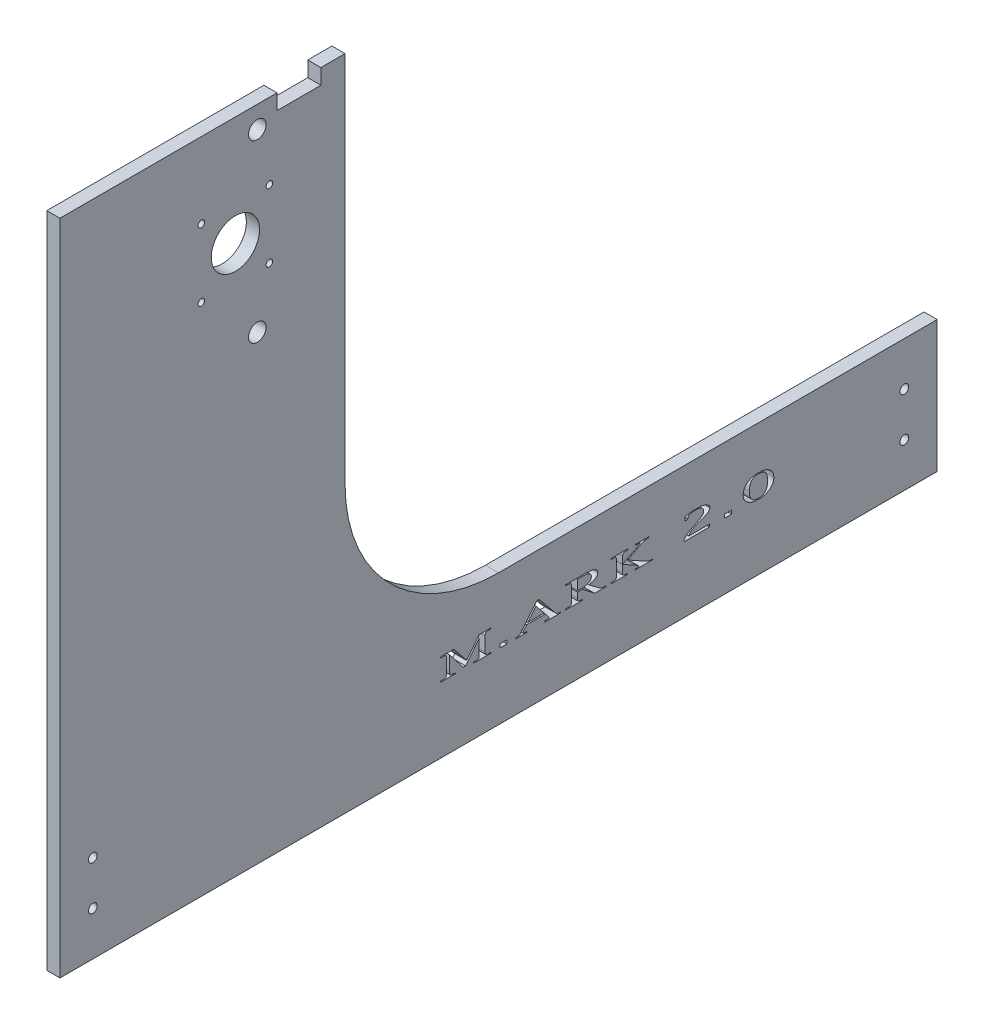
from build123d import *

# Parameters (mm, degrees)
SKETCH1_R           = 4
SKETCH1_R_2         = 1.5
SKETCH1_R_3         = 11
BOSS_EXTRUDE1_DEPTH = 6
SKETCH2_W           = 50
SKETCH2_H           = 300
BOSS_EXTRUDE2_DEPTH = 6
CUT_EXTRUDE1_REACH  = 8
SKETCH3_W           = 20
SKETCH3_H           = 7
CUT_EXTRUDE2_REACH  = 8
SKETCH4_R           = 2
SKETCH7_W           = 3.333333334
SKETCH7_H           = 1.666666667
SKETCH7_W_2         = 3.333333333
CUT_EXTRUDE4_DEPTH  = 7


with BuildPart() as part:
    # Sketch1 → Boss-Extrude1 (new body)
    with BuildSketch(Plane(origin=(0, 0, 0), x_dir=(0, 0, -1), z_dir=(1, 0, 0))):
        with BuildLine():
            Line((-80, -240), (-80, -300))
            Line((-80, -300), (320, -300))
            Line((320, -300), (320, -240))
            Line((320, -240), (120, -240))
            ThreePointArc((120, -240), (70.502525317, -219.497474683), (50, -170))
            Line((50, -170), (50, 0))
            Line((50, 0), (-30, 0))
            Line((-30, 0), (-30, -170))
            ThreePointArc((-30, -170), (-43.783723131, -213.011626335), (-80, -240))
        make_face()
        with Locations((10, -90)):
            Circle(SKETCH1_R, mode=Mode.SUBTRACT)
        with Locations((-15.5, -65.5)):
            Circle(SKETCH1_R_2, mode=Mode.SUBTRACT)
        with Locations((15.5, -65.5)):
            Circle(SKETCH1_R_2, mode=Mode.SUBTRACT)
        with Locations((0, -50)):
            Circle(SKETCH1_R_3, mode=Mode.SUBTRACT)
        with Locations((-15.5, -34.5)):
            Circle(SKETCH1_R_2, mode=Mode.SUBTRACT)
        with Locations((15.5, -34.5)):
            Circle(SKETCH1_R_2, mode=Mode.SUBTRACT)
        with Locations((10, -10)):
            Circle(SKETCH1_R, mode=Mode.SUBTRACT)
    extrude(amount=BOSS_EXTRUDE1_DEPTH)

    # Sketch2 → Boss-Extrude2 (add)
    with BuildSketch(Plane.ZY):
        with Locations((55, -150)):
            Rectangle(SKETCH2_W, SKETCH2_H)
    extrude(amount=-BOSS_EXTRUDE2_DEPTH)

    # Sketch3 → Cut-Extrude1 (cut, up to next)
    with BuildSketch(Plane(origin=(6, 0, 0), x_dir=(0, 0, -1), z_dir=(1, 0, 0)), mode=Mode.PRIVATE) as cut_extrude1_sk1:
        with Locations((29, -3.5)):
            Rectangle(SKETCH3_W, SKETCH3_H)
    cut_extrude1_tool1 = extrude(cut_extrude1_sk1.sketch, amount=-CUT_EXTRUDE1_REACH, mode=Mode.PRIVATE) & part.part
    add(cut_extrude1_tool1.solids().sort_by_distance((6, -3.5, -29))[0], mode=Mode.SUBTRACT)

    # Sketch4 → Cut-Extrude2 (cut, up to next)
    with BuildSketch(Plane(origin=(6, 0, 0), x_dir=(0, 0, -1), z_dir=(1, 0, 0)), mode=Mode.PRIVATE) as cut_extrude2_sk1:
        with Locations((-65, -280)):
            Circle(SKETCH4_R)
    cut_extrude2_tool1 = extrude(cut_extrude2_sk1.sketch, amount=-CUT_EXTRUDE2_REACH, mode=Mode.PRIVATE) & part.part
    add(cut_extrude2_tool1.solids().sort_by_distance((6, -280, 65))[0], mode=Mode.SUBTRACT)
    # Sketch4 → Cut-Extrude2 (cut, up to next)
    with BuildSketch(Plane(origin=(6, 0, 0), x_dir=(0, 0, -1), z_dir=(1, 0, 0)), mode=Mode.PRIVATE) as cut_extrude2_sk2:
        with Locations((-65, -260)):
            Circle(SKETCH4_R)
    cut_extrude2_tool2 = extrude(cut_extrude2_sk2.sketch, amount=-CUT_EXTRUDE2_REACH, mode=Mode.PRIVATE) & part.part
    add(cut_extrude2_tool2.solids().sort_by_distance((6, -260, 65))[0], mode=Mode.SUBTRACT)
    # Sketch4 → Cut-Extrude2 (cut, up to next)
    with BuildSketch(Plane(origin=(6, 0, 0), x_dir=(0, 0, -1), z_dir=(1, 0, 0)), mode=Mode.PRIVATE) as cut_extrude2_sk3:
        with Locations((305, -260)):
            Circle(SKETCH4_R)
    cut_extrude2_tool3 = extrude(cut_extrude2_sk3.sketch, amount=-CUT_EXTRUDE2_REACH, mode=Mode.PRIVATE) & part.part
    add(cut_extrude2_tool3.solids().sort_by_distance((6, -260, -305))[0], mode=Mode.SUBTRACT)
    # Sketch4 → Cut-Extrude2 (cut, up to next)
    with BuildSketch(Plane(origin=(6, 0, 0), x_dir=(0, 0, -1), z_dir=(1, 0, 0)), mode=Mode.PRIVATE) as cut_extrude2_sk4:
        with Locations((305, -280)):
            Circle(SKETCH4_R)
    cut_extrude2_tool4 = extrude(cut_extrude2_sk4.sketch, amount=-CUT_EXTRUDE2_REACH, mode=Mode.PRIVATE) & part.part
    add(cut_extrude2_tool4.solids().sort_by_distance((6, -280, -305))[0], mode=Mode.SUBTRACT)

    # Sketch7 → Cut-Extrude4 (cut, through all)
    with BuildSketch(Plane.ZY):
        with BuildLine():
            add(Edge.make_bspline(
                [(-238.5, -270.256410256), (-238.242114034, -270.252343671), (-237.738811781, -270.244407134), (-237.003782171, -270.177893717), (-236.308261947, -270.066183311), (-235.651611555, -269.91081166), (-235.034087912, -269.710853127), (-234.456150029, -269.465653825), (-233.916494442, -269.177207655), (-233.500028828, -268.89741033), (-233.191949631, -268.652940575), (-232.974639443, -268.46454701), (-232.771941527, -268.268602313), (-232.585258188, -268.06333758), (-232.413180763, -267.851480443), (-232.255676561, -267.632639472), (-232.115870291, -267.404616515), (-231.987238123, -267.171390658), (-231.874368904, -266.929967845), (-231.778637361, -266.680591883), (-231.696069776, -266.42467616), (-231.630231596, -266.160827195), (-231.578208722, -265.889976374), (-231.539784776, -265.611218338), (-231.517914357, -265.324871507), (-231.514528723, -265.131579388), (-231.512820513, -265.034054487)],
                knots=[0, 0, 0, 0, 0.000773551, 0.001509698, 0.002211827, 0.002885252, 0.003532039, 0.004156747, 0.004766196, 0.005365127, 0.005658896, 0.005945711, 0.006227623, 0.00650413, 0.006777566, 0.007046063, 0.007312338, 0.007579487, 0.007844758, 0.008111117, 0.00838036, 0.008650978, 0.00892638, 0.009207415, 0.00949472, 0.009787297, 0.009787297, 0.009787297, 0.009787297], degree=3))
            add(Edge.make_bspline(
                [(-231.512820513, -265.034054487), (-231.51447546, -264.934520114), (-231.517756045, -264.737214218), (-231.540353697, -264.445718581), (-231.575755005, -264.161321768), (-231.628160942, -263.885920689), (-231.693954296, -263.617388507), (-231.777149549, -263.357047721), (-231.871596428, -263.102472692), (-231.985715693, -262.858355362), (-232.109213646, -262.619325224), (-232.251791562, -262.391039438), (-232.40695848, -262.168554596), (-232.577081015, -261.95403091), (-232.763831398, -261.748699158), (-232.963236178, -261.548985404), (-233.176780128, -261.35631516), (-233.408019992, -261.1754439), (-233.649084656, -261.001034261), (-233.901958172, -260.838701967), (-234.165179538, -260.688485118), (-234.437999822, -260.54843613), (-234.719799438, -260.41719464), (-235.013628422, -260.30207742), (-235.316807755, -260.195271936), (-235.630219963, -260.099609515), (-235.953603572, -260.015055167), (-236.287325723, -259.943526776), (-236.631235511, -259.880889226), (-236.985606033, -259.831961939), (-237.349531659, -259.790951732), (-237.723735542, -259.763420564), (-238.108566357, -259.747468224), (-238.368441226, -259.74489328), (-238.5, -259.743589744)],
                knots=[0, 0, 0, 0, 0.000298585, 0.000591882, 0.000876626, 0.001157932, 0.001432437, 0.001705498, 0.00197747, 0.002246377, 0.002513398, 0.002784134, 0.003053109, 0.003326853, 0.003604844, 0.003885307, 0.004173274, 0.004467043, 0.004765581, 0.00506564, 0.005368025, 0.00567443, 0.00598545, 0.006300151, 0.006620726, 0.0069496, 0.007282909, 0.007623171, 0.007973274, 0.008331361, 0.008696148, 0.009071795, 0.009456744, 0.009851422, 0.009851422, 0.009851422, 0.009851422], degree=3))
            add(Edge.make_bspline(
                [(-238.5, -259.743589744), (-238.631558764, -259.744893316), (-238.891433614, -259.747468332), (-239.27626457, -259.76342015), (-239.650467937, -259.790953226), (-240.014395418, -259.831956578), (-240.36875923, -259.880908661), (-240.712693203, -259.943456833), (-241.046960401, -260.015442138), (-241.370657301, -260.098874208), (-241.683724493, -260.195719272), (-241.986389799, -260.302016178), (-242.280195783, -260.417210715), (-242.562001419, -260.548431924), (-242.834820186, -260.688486185), (-243.098041722, -260.838701825), (-243.350916032, -261.001033785), (-243.591977392, -261.175445921), (-243.823229406, -261.356307742), (-244.036729379, -261.549012213), (-244.236293044, -261.748602292), (-244.422111405, -261.953999739), (-244.59440586, -262.166862622), (-244.747055356, -262.39051269), (-244.890820293, -262.61822476), (-245.017751918, -262.855698208), (-245.126305421, -263.101662076), (-245.223969023, -263.3539212), (-245.306216132, -263.614043417), (-245.371312013, -263.88268714), (-245.424520586, -264.157932149), (-245.45947145, -264.441063492), (-245.482332207, -264.73186349), (-245.485550477, -264.928508151), (-245.487179487, -265.028044872)],
                knots=[0, 0, 0, 0, 0.000394677, 0.000779626, 0.001155274, 0.001520061, 0.001878147, 0.00222825, 0.002568512, 0.00290376, 0.003230719, 0.003551294, 0.003865995, 0.004177015, 0.00448342, 0.004785805, 0.005085864, 0.005384402, 0.005678171, 0.005966138, 0.006246601, 0.006524592, 0.00679677, 0.007067389, 0.007336423, 0.007604381, 0.007874286, 0.008142514, 0.008415575, 0.008692025, 0.008971362, 0.009256107, 0.009547406, 0.009845991, 0.009845991, 0.009845991, 0.009845991], degree=3))
            add(Edge.make_bspline(
                [(-245.487179487, -265.028044872), (-245.485546511, -265.126245624), (-245.48232089, -265.320221761), (-245.459526479, -265.607036709), (-245.424337937, -265.886112439), (-245.37195731, -266.157731378), (-245.303638964, -266.42174213), (-245.221729796, -266.678733907), (-245.124586777, -266.927849014), (-245.015822651, -267.171519487), (-244.885862723, -267.404481121), (-244.746510588, -267.632766841), (-244.588596581, -267.850760911), (-244.419017606, -268.06411094), (-244.231917895, -268.267795828), (-244.031410813, -268.465263776), (-243.813964238, -268.652849285), (-243.506400414, -268.897023722), (-243.091576533, -269.177155385), (-242.552994069, -269.466643086), (-241.974357015, -269.710312807), (-241.356441697, -269.910894298), (-240.699109386, -270.066378464), (-240.001559848, -270.178008622), (-239.263847659, -270.244323766), (-238.758551505, -270.252319152), (-238.5, -270.256410256)],
                knots=[0, 0, 0, 0, 0.00029458, 0.000581885, 0.000862655, 0.001138058, 0.001411112, 0.001680355, 0.001946713, 0.002212966, 0.002480114, 0.00274639, 0.003014887, 0.003287065, 0.003563572, 0.00384405, 0.004130865, 0.004424633, 0.005021904, 0.005629589, 0.006256141, 0.006902928, 0.007576354, 0.00828046, 0.009020597, 0.009796151, 0.009796151, 0.009796151, 0.009796151], degree=3))
        make_face()
        with BuildLine():
            add(Edge.make_bspline(
                [(-238.493990385, -269.871794872), (-238.656449419, -269.868913238), (-238.973124719, -269.863296177), (-239.43350454, -269.802860722), (-239.867809896, -269.709864484), (-240.274702105, -269.577910095), (-240.656358006, -269.408754663), (-241.008830498, -269.199105282), (-241.338042409, -268.955165267), (-241.530428858, -268.762553058), (-241.627003205, -268.665865385)],
                knots=[0, 0, 0, 0, 0.000487113, 0.00094951, 0.00139037, 0.001817974, 0.002230459, 0.002639976, 0.003046227, 0.003455709, 0.003455709, 0.003455709, 0.003455709], degree=3))
            add(Edge.make_bspline(
                [(-241.627003205, -268.665865385), (-241.711570058, -268.570046377), (-241.884967926, -268.373576823), (-242.092385799, -268.024489849), (-242.271298313, -267.633593693), (-242.416391631, -267.196013726), (-242.529450065, -266.713222585), (-242.6106031, -266.184862345), (-242.658249863, -265.609856335), (-242.663789634, -265.211098115), (-242.666666667, -265.00400641)],
                knots=[0, 0, 0, 0, 0.000382675, 0.000784646, 0.001212212, 0.001670845, 0.002164988, 0.002698194, 0.003273124, 0.003894325, 0.003894325, 0.003894325, 0.003894325], degree=3))
            add(Edge.make_bspline(
                [(-242.666666667, -265.00400641), (-242.663767442, -264.796248222), (-242.65817499, -264.395493563), (-242.6106877, -263.817816796), (-242.529689557, -263.287399649), (-242.416303754, -262.804019711), (-242.271733346, -262.366880156), (-242.092349453, -261.977465227), (-241.884946185, -261.630332567), (-241.711569386, -261.435281999), (-241.627003205, -261.340144231)],
                knots=[0, 0, 0, 0, 0.000623203, 0.001202126, 0.001737311, 0.002231454, 0.002690087, 0.003115833, 0.003516098, 0.003897234, 0.003897234, 0.003897234, 0.003897234], degree=3))
            add(Edge.make_bspline(
                [(-241.627003205, -261.340144231), (-241.529062621, -261.242821196), (-241.333917671, -261.048906703), (-241.001341894, -260.802629479), (-240.642816566, -260.592693951), (-240.255502239, -260.422138549), (-239.840457835, -260.289584894), (-239.397990566, -260.197451877), (-238.928372989, -260.136575417), (-238.605703414, -260.131046229), (-238.439903846, -260.128205128)],
                knots=[0, 0, 0, 0, 0.000413767, 0.000824424, 0.001237396, 0.001658016, 0.002091339, 0.002541989, 0.003012337, 0.003509459, 0.003509459, 0.003509459, 0.003509459], degree=3))
            add(Edge.make_bspline(
                [(-238.439903846, -260.128205128), (-238.283440873, -260.131068001), (-237.978050617, -260.136655864), (-237.532457463, -260.197771254), (-237.109966143, -260.289969395), (-236.710659472, -260.423363114), (-236.334352378, -260.592971658), (-235.983500251, -260.804264838), (-235.653638346, -261.049921006), (-235.457684464, -261.242921746), (-235.358974359, -261.340144231)],
                knots=[0, 0, 0, 0, 0.000469097, 0.0009156, 0.00134668, 0.00176477, 0.002176252, 0.002582325, 0.002991381, 0.003406606, 0.003406606, 0.003406606, 0.003406606], degree=3))
            add(Edge.make_bspline(
                [(-235.358974359, -261.340144231), (-235.275795095, -261.434672969), (-235.104542811, -261.629291936), (-234.899585178, -261.975559972), (-234.7227563, -262.364487853), (-234.579030457, -262.801240934), (-234.468612982, -263.284902735), (-234.389825552, -263.81597502), (-234.341622046, -264.394139275), (-234.33616614, -264.795574101), (-234.333333333, -265.00400641)],
                knots=[0, 0, 0, 0, 0.000377034, 0.00077625, 0.001201161, 0.001657259, 0.002152893, 0.002687775, 0.003266698, 0.003891903, 0.003891903, 0.003891903, 0.003891903], degree=3))
            add(Edge.make_bspline(
                [(-234.333333333, -265.00400641), (-234.336152418, -265.211105968), (-234.341580608, -265.609879309), (-234.389989388, -266.184679538), (-234.468481347, -266.713143091), (-234.579671177, -267.195913329), (-234.722737841, -267.633454751), (-234.899512631, -268.024447981), (-235.105078434, -268.372818064), (-235.275858187, -268.569932489), (-235.358974359, -268.665865385)],
                knots=[0, 0, 0, 0, 0.0006212, 0.001196131, 0.001729032, 0.002222716, 0.002680714, 0.003107449, 0.003508375, 0.003888504, 0.003888504, 0.003888504, 0.003888504], degree=3))
            add(Edge.make_bspline(
                [(-235.358974359, -268.665865385), (-235.455545886, -268.762559831), (-235.647926718, -268.955185532), (-235.977180615, -269.199024698), (-236.330017041, -269.409373477), (-236.712317091, -269.576941664), (-237.119266993, -269.710656122), (-237.55389986, -269.802503979), (-238.014836663, -269.863369635), (-238.331524777, -269.868938145), (-238.493990385, -269.871794872)],
                knots=[0, 0, 0, 0, 0.000409483, 0.000815734, 0.001225251, 0.001639566, 0.002065264, 0.002508081, 0.002970479, 0.003457592, 0.003457592, 0.003457592, 0.003457592], degree=3))
        make_face(mode=Mode.SUBTRACT)
        with Locations((-224.564102564, -269.166666667)):
            Rectangle(SKETCH7_W, SKETCH7_H)
        with BuildLine():
            Line((-204.538461538, -270), (-204.538461538, -269.338942308))
            add(Edge.make_bspline(
                [(-204.538461538, -269.338942308), (-204.635093088, -269.198421844), (-204.830352917, -268.914477297), (-205.167581589, -268.513737097), (-205.543836631, -268.130039318), (-205.959944548, -267.763891813), (-206.413451092, -267.412136952), (-206.908482609, -267.08028336), (-207.441293942, -266.76283987), (-207.816594978, -266.570471152), (-208.008012821, -266.472355769)],
                knots=[0, 0, 0, 0, 0.000511379, 0.001033324, 0.001568784, 0.002122256, 0.00269484, 0.003289329, 0.003909094, 0.004554254, 0.004554254, 0.004554254, 0.004554254], degree=3))
            Line((-208.008012821, -266.472355769), (-209.424278846, -265.797275641))
            add(Edge.make_bspline(
                [(-209.424278846, -265.797275641), (-209.620956796, -265.703871974), (-209.998370518, -265.524635685), (-210.535114256, -265.255126807), (-211.022368661, -265.00408286), (-211.45759343, -264.766275761), (-211.840491405, -264.541596292), (-212.173479116, -264.334601189), (-212.455544969, -264.142377967), (-212.691710108, -263.962680863), (-212.887150364, -263.783417569), (-213.054503784, -263.603430828), (-213.196732671, -263.416187208), (-213.310925814, -263.220566372), (-213.402582456, -263.019614008), (-213.46675239, -262.811655783), (-213.506610587, -262.59702471), (-213.510734924, -262.451429069), (-213.512820513, -262.377804487)],
                knots=[0, 0, 0, 0, 0.000653171, 0.001253397, 0.001801723, 0.002297491, 0.002741033, 0.003133436, 0.003473486, 0.003764785, 0.004022833, 0.004268085, 0.004501258, 0.004726634, 0.004946303, 0.005162362, 0.005378085, 0.005598766, 0.005598766, 0.005598766, 0.005598766], degree=3))
            add(Edge.make_bspline(
                [(-213.512820513, -262.377804487), (-213.509642454, -262.294808779), (-213.503389592, -262.131513914), (-213.456905514, -261.893016819), (-213.376717346, -261.668013037), (-213.269531618, -261.454068647), (-213.125271976, -261.255673835), (-212.952772613, -261.069044969), (-212.747890349, -260.896512169), (-212.515732704, -260.736994923), (-212.257760082, -260.592921715), (-211.976508807, -260.470317042), (-211.676496695, -260.362540356), (-211.355709382, -260.278339503), (-211.015466436, -260.209193962), (-210.654672755, -260.162193517), (-210.273420185, -260.13412569), (-210.012602835, -260.13021055), (-209.87900641, -260.128205128)],
                knots=[0, 0, 0, 0, 0.000248914, 0.00048974, 0.000725422, 0.000963727, 0.001204978, 0.001458722, 0.001724455, 0.002006729, 0.002302668, 0.002609388, 0.002926185, 0.003258071, 0.003603396, 0.003967164, 0.004348805, 0.004749571, 0.004749571, 0.004749571, 0.004749571], degree=3))
            add(Edge.make_bspline(
                [(-209.87900641, -260.128205128), (-209.730740591, -260.129831017), (-209.439386401, -260.133026017), (-209.011768321, -260.155509542), (-208.601989823, -260.190655141), (-208.21021397, -260.242515865), (-207.836878981, -260.311042221), (-207.480200652, -260.390670984), (-207.141691867, -260.484959365), (-206.925819061, -260.564175041), (-206.820112179, -260.602964744)],
                knots=[0, 0, 0, 0, 0.000444784, 0.000874036, 0.001284277, 0.001678359, 0.0020591, 0.002422608, 0.00277454, 0.003112227, 0.003112227, 0.003112227, 0.003112227], degree=3))
            add(Edge.make_bspline(
                [(-206.820112179, -260.602964744), (-206.781031032, -260.621330555), (-206.700620915, -260.659118519), (-206.595091109, -260.751344789), (-206.502359657, -260.872166692), (-206.423653489, -261.022811296), (-206.353605555, -261.199953761), (-206.296275598, -261.406145927), (-206.251145819, -261.640780542), (-206.230176805, -261.807412009), (-206.219150641, -261.895032051)],
                knots=[0, 0, 0, 0, 0.000129032, 0.000265485, 0.000415351, 0.000583859, 0.000773572, 0.000985997, 0.001224857, 0.001489743, 0.001489743, 0.001489743, 0.001489743], degree=3))
            Line((-206.219150641, -261.895032051), (-206.205128205, -262.051282051))
            Line((-206.205128205, -262.051282051), (-204.923076923, -262.051282051))
            Line((-204.923076923, -262.051282051), (-204.923076923, -260.384615385))
            add(Edge.make_bspline(
                [(-204.923076923, -260.384615385), (-205.16054815, -260.333344013), (-205.62973806, -260.232043277), (-206.328587829, -260.102719659), (-207.013078832, -259.991611462), (-207.6830922, -259.901684074), (-208.338352073, -259.83114754), (-208.978956996, -259.780970999), (-209.604918195, -259.749613336), (-210.017860583, -259.745579521), (-210.221554487, -259.743589744)],
                knots=[0, 0, 0, 0, 0.000728795, 0.001439936, 0.002131857, 0.002808958, 0.003467748, 0.004108729, 0.004736452, 0.005347512, 0.005347512, 0.005347512, 0.005347512], degree=3))
            add(Edge.make_bspline(
                [(-210.221554487, -259.743589744), (-210.439939523, -259.74604896), (-210.866965889, -259.750857671), (-211.492717486, -259.78394211), (-212.08802594, -259.844860846), (-212.653941266, -259.925329348), (-213.189234889, -260.03224137), (-213.695324569, -260.158016833), (-214.169496463, -260.314100357), (-214.611266374, -260.487416697), (-215.011511421, -260.67944308), (-215.363298567, -260.884616065), (-215.660400553, -261.105005181), (-215.905155698, -261.338675315), (-216.097046761, -261.586444643), (-216.234446829, -261.849105253), (-216.318983474, -262.126242259), (-216.328540709, -262.316467547), (-216.333333333, -262.411858974)],
                knots=[0, 0, 0, 0, 0.000655158, 0.001281085, 0.001879065, 0.002449908, 0.002995199, 0.003516033, 0.004013316, 0.004491692, 0.004938771, 0.005343819, 0.005711608, 0.006045945, 0.006356054, 0.006647243, 0.006931218, 0.007216863, 0.007216863, 0.007216863, 0.007216863], degree=3))
            add(Edge.make_bspline(
                [(-216.333333333, -262.411858974), (-216.329887859, -262.476856281), (-216.322955874, -262.607625043), (-216.277340188, -262.802525658), (-216.200014563, -262.994780486), (-216.08949875, -263.182913367), (-215.952467682, -263.371281535), (-215.781671447, -263.554942835), (-215.583125469, -263.739439305), (-215.353497421, -263.921333129), (-215.093999916, -264.102044072), (-214.803005434, -264.279304182), (-214.482068555, -264.455562076), (-214.130418972, -264.628878342), (-213.750514548, -264.803965075), (-213.337891871, -264.973033088), (-212.896165452, -265.143887026), (-212.58899803, -265.251281271), (-212.431089744, -265.306490385)],
                knots=[0, 0, 0, 0, 0.000194971, 0.000392263, 0.000597228, 0.000814388, 0.001045175, 0.001294733, 0.001565462, 0.001857662, 0.002172752, 0.002513567, 0.00287936, 0.003270852, 0.003689464, 0.004134022, 0.004608346, 0.005110156, 0.005110156, 0.005110156, 0.005110156], degree=3))
            Line((-212.431089744, -265.306490385), (-210.858573718, -265.879407051))
            add(Edge.make_bspline(
                [(-210.858573718, -265.879407051), (-210.704770478, -265.936232048), (-210.405345195, -266.046859371), (-209.971065328, -266.218671641), (-209.565686743, -266.395416724), (-209.185058211, -266.570664837), (-208.833365514, -266.751836842), (-208.506043029, -266.930668188), (-208.206868267, -267.113610671), (-207.933928839, -267.296929251), (-207.688552161, -267.483714795), (-207.469481791, -267.672019435), (-207.275965927, -267.861603119), (-207.111466184, -268.054748467), (-206.970782927, -268.247908737), (-206.858071917, -268.444408611), (-206.772088053, -268.643459919), (-206.735743285, -268.779532218), (-206.717948718, -268.846153846)],
                knots=[0, 0, 0, 0, 0.000491892, 0.000957619, 0.001400834, 0.001818468, 0.002214454, 0.002587444, 0.002937185, 0.003266101, 0.003573402, 0.003861732, 0.004132283, 0.004385195, 0.004622023, 0.004848128, 0.005063554, 0.005270205, 0.005270205, 0.005270205, 0.005270205], degree=3))
            Line((-206.717948718, -268.846153846), (-216.205128205, -268.846153846))
            Line((-216.205128205, -268.846153846), (-216.205128205, -270))
            Line((-216.205128205, -270), (-204.538461538, -270))
        make_face()
        with BuildLine():
            Line((-176.538461538, -264.943910256), (-176.538461538, -268.205128205))
            add(Edge.make_bspline(
                [(-176.538461538, -268.205128205), (-176.538849667, -268.281289722), (-176.539585831, -268.425745528), (-176.555135562, -268.630081346), (-176.572760956, -268.811161828), (-176.603259572, -268.967678274), (-176.639161711, -269.101770661), (-176.688518505, -269.210525349), (-176.740157097, -269.300057368), (-176.811049377, -269.366725163), (-176.90534511, -269.413255047), (-177.026718977, -269.45410544), (-177.183014019, -269.491476109), (-177.373679315, -269.524546359), (-177.599767925, -269.551720481), (-177.859650698, -269.57516025), (-178.154817032, -269.595697105), (-178.363349392, -269.603335135), (-178.473557692, -269.607371795)],
                knots=[0, 0, 0, 0, 0.000228401, 0.000433208, 0.000614606, 0.000773719, 0.0009113, 0.001029676, 0.001131386, 0.001219254, 0.00131694, 0.001444281, 0.001603154, 0.001798454, 0.002024559, 0.002286083, 0.002581234, 0.002912061, 0.002912061, 0.002912061, 0.002912061], degree=3))
            Line((-178.473557692, -269.607371795), (-178.717948718, -269.615384615))
            Line((-178.717948718, -269.615384615), (-178.717948718, -270))
            Line((-178.717948718, -270), (-171.153846154, -270))
            Line((-171.153846154, -270), (-171.153846154, -269.615384615))
            Line((-171.153846154, -269.615384615), (-171.416266026, -269.607371795))
            add(Edge.make_bspline(
                [(-171.416266026, -269.607371795), (-171.549169273, -269.60251664), (-171.800375897, -269.593339686), (-172.155627693, -269.572963593), (-172.468478124, -269.550753782), (-172.738687585, -269.519311464), (-172.967329957, -269.490417546), (-173.152151842, -269.451253855), (-173.295963063, -269.414868503), (-173.403979633, -269.36711258), (-173.485208496, -269.30186648), (-173.546952602, -269.213385971), (-173.601075103, -269.104117656), (-173.644043227, -268.970341761), (-173.677540834, -268.813286418), (-173.700096774, -268.631646352), (-173.717126496, -268.426466759), (-173.717665787, -268.281291887), (-173.717948718, -268.205128205)],
                knots=[0, 0, 0, 0, 0.00039896, 0.000754093, 0.001067516, 0.001339613, 0.001570216, 0.0017584, 0.001906163, 0.002014595, 0.002110016, 0.002214587, 0.002335528, 0.002474891, 0.002634809, 0.002816693, 0.003023644, 0.003252045, 0.003252045, 0.003252045, 0.003252045], degree=3))
            Line((-173.717948718, -268.205128205), (-173.717948718, -261.794871795))
            add(Edge.make_bspline(
                [(-173.717948718, -261.794871795), (-173.717681982, -261.718040042), (-173.717175661, -261.572196945), (-173.700101705, -261.366347918), (-173.677528747, -261.184717944), (-173.644079694, -261.027631823), (-173.600964439, -260.893949658), (-173.547522992, -260.784879629), (-173.485090569, -260.69798415), (-173.403760669, -260.634774845), (-173.295406663, -260.589838033), (-173.152494873, -260.55195759), (-172.966964882, -260.516717969), (-172.738909397, -260.485631171), (-172.468186702, -260.45884086), (-172.155786532, -260.431891199), (-171.800344135, -260.413018203), (-171.549158283, -260.403613479), (-171.416266026, -260.398637821)],
                knots=[0, 0, 0, 0, 0.000230403, 0.000437355, 0.000619239, 0.000779157, 0.00091852, 0.001039461, 0.001142427, 0.001236599, 0.001344195, 0.001491958, 0.001679747, 0.001910351, 0.002182234, 0.002495817, 0.00285095, 0.00324991, 0.00324991, 0.00324991, 0.00324991], degree=3))
            Line((-171.416266026, -260.398637821), (-171.153846154, -260.384615385))
            Line((-171.153846154, -260.384615385), (-171.153846154, -260))
            Line((-171.153846154, -260), (-179.102564103, -260))
            Line((-179.102564103, -260), (-179.102564103, -260.384615385))
            Line((-179.102564103, -260.384615385), (-178.840144231, -260.398637821))
            add(Edge.make_bspline(
                [(-178.840144231, -260.398637821), (-178.706585526, -260.403632298), (-178.453401053, -260.413100224), (-178.095276706, -260.43179936), (-177.780222302, -260.458903899), (-177.508123759, -260.485450316), (-177.279471442, -260.516850512), (-177.094419355, -260.55150268), (-176.95250897, -260.590337205), (-176.844906291, -260.634204337), (-176.765129541, -260.69818048), (-176.705284965, -260.785568146), (-176.650779843, -260.893477036), (-176.611243992, -261.028136105), (-176.576006317, -261.184463079), (-176.557224734, -261.366569131), (-176.538959162, -261.572156127), (-176.538633239, -261.718025958), (-176.538461538, -261.794871795)],
                knots=[0, 0, 0, 0, 0.000400961, 0.000760094, 0.001075674, 0.001349549, 0.001580153, 0.001767942, 0.001913778, 0.002021374, 0.002113978, 0.002215748, 0.002336689, 0.002475432, 0.00263535, 0.00281698, 0.003023931, 0.003254335, 0.003254335, 0.003254335, 0.003254335], degree=3))
            Line((-176.538461538, -261.794871795), (-176.538461538, -264.905849359))
            Line((-176.538461538, -264.905849359), (-182.640224359, -261.806891026))
            add(Edge.make_bspline(
                [(-182.640224359, -261.806891026), (-182.720438416, -261.759626039), (-182.876523932, -261.66765488), (-183.101149462, -261.532093239), (-183.310646092, -261.40494341), (-183.504895389, -261.287736546), (-183.682542634, -261.176111674), (-183.847753806, -261.078273518), (-183.993196995, -260.982078736), (-184.125893962, -260.899077398), (-184.242848941, -260.822410519), (-184.343771643, -260.753694395), (-184.427992719, -260.691875558), (-184.499829939, -260.643609619), (-184.552484642, -260.598073728), (-184.594242972, -260.566073163), (-184.61809939, -260.538174829), (-184.624960303, -260.520956204), (-184.627403846, -260.514823718)],
                knots=[0, 0, 0, 0, 0.000279309, 0.000543497, 0.000787074, 0.001014506, 0.001224087, 0.001416478, 0.0015904, 0.001747112, 0.001886013, 0.002009921, 0.002113314, 0.002199475, 0.002269243, 0.002321825, 0.002357491, 0.00237722, 0.00237722, 0.00237722, 0.00237722], degree=3))
            add(Edge.make_bspline(
                [(-184.627403846, -260.514823718), (-184.617974218, -260.503837871), (-184.587295936, -260.468096598), (-184.482330968, -260.457566016), (-184.333217165, -260.428147842), (-184.116175941, -260.415310741), (-183.841177835, -260.400333878), (-183.503576608, -260.391540315), (-183.105014766, -260.385505737), (-182.819188847, -260.384925711), (-182.666266026, -260.384615385)],
                knots=[0, 0, 0, 0, 4.2494e-05, 0.000138251, 0.00029436, 0.000509459, 0.000784257, 0.001122946, 0.001521629, 0.001980368, 0.001980368, 0.001980368, 0.001980368], degree=3))
            Line((-182.666266026, -260.384615385), (-182.423878205, -260.384615385))
            Line((-182.423878205, -260.384615385), (-182.423878205, -260))
            Line((-182.423878205, -260), (-188.563701923, -260))
            Line((-188.563701923, -260), (-188.563701923, -260.384615385))
            Line((-188.563701923, -260.384615385), (-188.333333333, -260.398637821))
            add(Edge.make_bspline(
                [(-188.333333333, -260.398637821), (-188.207792772, -260.40241898), (-187.970026828, -260.409580258), (-187.63210173, -260.42320717), (-187.333058291, -260.440277466), (-187.070904908, -260.453609429), (-186.848114088, -260.477089805), (-186.662165443, -260.497991587), (-186.514987011, -260.521133502), (-186.411602885, -260.543729404), (-186.337952765, -260.570415998), (-186.271969814, -260.594445852), (-186.193880796, -260.628960936), (-186.1007006, -260.668837986), (-185.994647485, -260.717219145), (-185.874486878, -260.773380119), (-185.74069676, -260.837002098), (-185.593656047, -260.910204681), (-185.432679698, -260.989557153), (-185.257517768, -261.075930072), (-185.069250105, -261.170153543), (-184.866970822, -261.272406336), (-184.650995401, -261.382009401), (-184.421863608, -261.501305277), (-184.178708276, -261.626645851), (-184.011751075, -261.7127383), (-183.926282051, -261.756810897)],
                knots=[0, 0, 0, 0, 0.000376794, 0.000713625, 0.001014533, 0.001275442, 0.00150088, 0.001686488, 0.001836661, 0.001947925, 0.002003041, 0.002071502, 0.002158567, 0.002259047, 0.002375595, 0.002508231, 0.002656968, 0.002820017, 0.003000983, 0.003195387, 0.003405914, 0.003632568, 0.003875353, 0.00413249, 0.004407543, 0.004696032, 0.004696032, 0.004696032, 0.004696032], degree=3))
            Line((-183.926282051, -261.756810897), (-178.802083333, -264.358974359))
            Line((-178.802083333, -264.358974359), (-185.823317308, -268.257211538))
            add(Edge.make_bspline(
                [(-185.823317308, -268.257211538), (-185.9654931, -268.334763547), (-186.236185472, -268.482416933), (-186.622265621, -268.691106823), (-186.968747456, -268.873593384), (-187.27514436, -269.030101378), (-187.541315543, -269.160960184), (-187.768052226, -269.265199024), (-187.953742067, -269.346205214), (-188.11071876, -269.406813049), (-188.262484537, -269.445566166), (-188.427677936, -269.483227047), (-188.620180883, -269.510740934), (-188.837721435, -269.539488514), (-189.081604942, -269.56309995), (-189.350787228, -269.582684382), (-189.646643975, -269.598845486), (-189.852414381, -269.60576128), (-189.959935897, -269.609375)],
                knots=[0, 0, 0, 0, 0.000485855, 0.000925032, 0.001316606, 0.001660627, 0.001957169, 0.002206349, 0.002409148, 0.002565064, 0.002710362, 0.002878536, 0.003073177, 0.00329332, 0.003536896, 0.00380807, 0.004102977, 0.004425717, 0.004425717, 0.004425717, 0.004425717], degree=3))
            Line((-189.959935897, -269.609375), (-190.244391026, -269.615384615))
            Line((-190.244391026, -269.615384615), (-190.244391026, -270))
            Line((-190.244391026, -270), (-182.093349359, -270))
            Line((-182.093349359, -270), (-182.093349359, -269.615384615))
            Line((-182.093349359, -269.615384615), (-182.335737179, -269.615384615))
            add(Edge.make_bspline(
                [(-182.335737179, -269.615384615), (-182.464621061, -269.615228889), (-182.705724309, -269.614937571), (-183.042273349, -269.607023826), (-183.328457663, -269.594321465), (-183.563070794, -269.573910152), (-183.749459398, -269.552818682), (-183.881261451, -269.522840048), (-183.975862311, -269.495462973), (-184.002666656, -269.455607764), (-184.012419872, -269.441105769)],
                knots=[0, 0, 0, 0, 0.000386624, 0.000723258, 0.001010059, 0.001245288, 0.001431144, 0.001568682, 0.00165838, 0.001709687, 0.001709687, 0.001709687, 0.001709687], degree=3))
            add(Edge.make_bspline(
                [(-184.012419872, -269.441105769), (-184.011673979, -269.430281498), (-184.009974447, -269.40561817), (-183.990959055, -269.366345851), (-183.961349021, -269.320812697), (-183.915007228, -269.27073968), (-183.857543798, -269.213343608), (-183.78702938, -269.14873405), (-183.701851847, -269.079135926), (-183.605048212, -269.000509333), (-183.491317883, -268.919969488), (-183.368192436, -268.827740395), (-183.2268923, -268.735690502), (-183.074846725, -268.633269421), (-182.911081685, -268.521604403), (-182.730530692, -268.409184821), (-182.537601395, -268.288264726), (-182.404549133, -268.205740676), (-182.335737179, -268.163060897)],
                knots=[0, 0, 0, 0, 3.2301e-05, 7.3598e-05, 0.000128604, 0.000195314, 0.00027747, 0.000372469, 0.000481988, 0.00060744, 0.000746472, 0.000899936, 0.001068836, 0.001252182, 0.001449972, 0.001663377, 0.001890155, 0.002133072, 0.002133072, 0.002133072, 0.002133072], degree=3))
            Line((-182.335737179, -268.163060897), (-176.538461538, -264.943910256))
        make_face()
        with BuildLine():
            Line((-156, -265.641025641), (-156, -268.205128205))
            add(Edge.make_bspline(
                [(-156, -268.205128205), (-156.000361812, -268.281294641), (-156.001048062, -268.425759776), (-156.016929921, -268.630033516), (-156.033513527, -268.811440723), (-156.067297823, -268.967476181), (-156.102776488, -269.101668164), (-156.151635258, -269.21123127), (-156.205878525, -269.299526264), (-156.276480082, -269.366777011), (-156.371458191, -269.413644695), (-156.493738059, -269.453687263), (-156.649280281, -269.49110919), (-156.837833648, -269.524823894), (-157.061311048, -269.551681481), (-157.318519049, -269.575096899), (-157.609676751, -269.595658798), (-157.81487176, -269.603327742), (-157.923076923, -269.607371795)],
                knots=[0, 0, 0, 0, 0.000228401, 0.000433208, 0.000614606, 0.000774109, 0.00091169, 0.001030066, 0.001132856, 0.001220724, 0.001318409, 0.001447643, 0.001606516, 0.001797872, 0.00202199, 0.002281519, 0.002572674, 0.002897496, 0.002897496, 0.002897496, 0.002897496], degree=3))
            Line((-157.923076923, -269.607371795), (-158.179487179, -269.615384615))
            Line((-158.179487179, -269.615384615), (-158.179487179, -270))
            Line((-158.179487179, -270), (-150.615384615, -270))
            Line((-150.615384615, -270), (-150.615384615, -269.615384615))
            Line((-150.615384615, -269.615384615), (-150.877804487, -269.607371795))
            add(Edge.make_bspline(
                [(-150.877804487, -269.607371795), (-151.010707734, -269.60251664), (-151.261914358, -269.593339686), (-151.617166154, -269.572963593), (-151.930016585, -269.550753782), (-152.200226047, -269.519311464), (-152.428868419, -269.490417546), (-152.613690303, -269.451253855), (-152.757501524, -269.414868503), (-152.865518094, -269.36711258), (-152.946746958, -269.30186648), (-153.008491063, -269.213385971), (-153.062613565, -269.104117656), (-153.105581688, -268.970341761), (-153.139079295, -268.813286418), (-153.161635235, -268.631646352), (-153.178664958, -268.426466759), (-153.179204249, -268.281291887), (-153.179487179, -268.205128205)],
                knots=[0, 0, 0, 0, 0.00039896, 0.000754093, 0.001067516, 0.001339613, 0.001570216, 0.0017584, 0.001906163, 0.002014595, 0.002110016, 0.002214587, 0.002335528, 0.002474891, 0.002634809, 0.002816693, 0.003023644, 0.003252045, 0.003252045, 0.003252045, 0.003252045], degree=3))
            Line((-153.179487179, -268.205128205), (-153.179487179, -261.794871795))
            add(Edge.make_bspline(
                [(-153.179487179, -261.794871795), (-153.179220444, -261.718040042), (-153.178714122, -261.572196945), (-153.161640166, -261.366347918), (-153.139067208, -261.184717944), (-153.105618155, -261.027631823), (-153.062502901, -260.893949658), (-153.009061454, -260.784879629), (-152.946629031, -260.69798415), (-152.865299131, -260.634774845), (-152.756945124, -260.589838033), (-152.614033334, -260.55195759), (-152.428503344, -260.516717969), (-152.200447858, -260.485631171), (-151.929725164, -260.45884086), (-151.617324994, -260.431891199), (-151.261882597, -260.413018203), (-151.010696745, -260.403613479), (-150.877804487, -260.398637821)],
                knots=[0, 0, 0, 0, 0.000230403, 0.000437355, 0.000619239, 0.000779157, 0.00091852, 0.001039461, 0.001142427, 0.001236599, 0.001344195, 0.001491958, 0.001679747, 0.001910351, 0.002182234, 0.002495817, 0.00285095, 0.00324991, 0.00324991, 0.00324991, 0.00324991], degree=3))
            Line((-150.877804487, -260.398637821), (-150.615384615, -260.384615385))
            Line((-150.615384615, -260.384615385), (-150.615384615, -260))
            Line((-150.615384615, -260), (-155.455128205, -260))
            Line((-155.455128205, -260), (-157.903044872, -260))
            Line((-157.903044872, -260), (-158.990785256, -260))
            add(Edge.make_bspline(
                [(-158.990785256, -260), (-159.242557353, -260.001733236), (-159.730265605, -260.00509069), (-160.437666488, -260.036199922), (-161.096607313, -260.082415294), (-161.706828672, -260.150098298), (-162.267968606, -260.236763776), (-162.780156625, -260.344801701), (-163.244412062, -260.469641341), (-163.661588852, -260.614136978), (-164.028366499, -260.782600555), (-164.34999198, -260.965803191), (-164.620477756, -261.172499828), (-164.843330367, -261.398868024), (-165.01709096, -261.646349212), (-165.140613522, -261.914940293), (-165.218152986, -262.203225463), (-165.226519537, -262.402690458), (-165.230769231, -262.50400641)],
                knots=[0, 0, 0, 0, 0.000755275, 0.001463044, 0.00212385, 0.002736621, 0.003304402, 0.003826547, 0.004306188, 0.004745882, 0.005149243, 0.005515495, 0.005854061, 0.006167131, 0.00646499, 0.006756282, 0.007050235, 0.007353673, 0.007353673, 0.007353673, 0.007353673], degree=3))
            add(Edge.make_bspline(
                [(-165.230769231, -262.50400641), (-165.227722981, -262.589026985), (-165.221700227, -262.757121559), (-165.172647111, -263.003607221), (-165.089324192, -263.238570701), (-164.973267004, -263.461832629), (-164.828785793, -263.677420111), (-164.64538002, -263.876563187), (-164.433779725, -264.068030255), (-164.189958565, -264.249064965), (-163.911721932, -264.416043166), (-163.602807186, -264.574640844), (-163.260728317, -264.719829808), (-162.886941616, -264.856083769), (-162.481087093, -264.98155844), (-162.042357228, -265.095218487), (-161.571955504, -265.199482615), (-161.245950666, -265.258222525), (-161.078125, -265.288461538)],
                knots=[0, 0, 0, 0, 0.000254911, 0.000503986, 0.000750446, 0.001000405, 0.001257097, 0.001526601, 0.001810251, 0.002112336, 0.002435964, 0.002782681, 0.003153295, 0.003550011, 0.003975794, 0.004427174, 0.004909314, 0.005420858, 0.005420858, 0.005420858, 0.005420858], degree=3))
            Line((-161.078125, -265.288461538), (-165.036458333, -268.275240385))
            add(Edge.make_bspline(
                [(-165.036458333, -268.275240385), (-165.139873948, -268.348809692), (-165.337030387, -268.489065714), (-165.618791121, -268.686752069), (-165.871496169, -268.862586603), (-166.097249481, -269.011809292), (-166.294523409, -269.139312687), (-166.463359295, -269.24313736), (-166.604348889, -269.323874754), (-166.755867585, -269.404741434), (-166.944784455, -269.473624805), (-167.188217074, -269.530981501), (-167.461256675, -269.568674493), (-167.653854669, -269.57697782), (-167.754807692, -269.581330128)],
                knots=[0, 0, 0, 0, 0.000380741, 0.000725862, 0.001032588, 0.001304272, 0.001537652, 0.00173726, 0.001898763, 0.002025092, 0.002252048, 0.002499352, 0.002774434, 0.003077455, 0.003077455, 0.003077455, 0.003077455], degree=3))
            add(Edge.make_bspline(
                [(-167.754807692, -269.581330128), (-167.773494023, -269.582877613), (-167.816153823, -269.58641043), (-167.888403908, -269.586778041), (-167.976467453, -269.59202986), (-168.081326457, -269.59542884), (-168.202820808, -269.600267237), (-168.341106182, -269.600735888), (-168.495315293, -269.605825129), (-168.603496367, -269.608153407), (-168.66025641, -269.609375)],
                knots=[0, 0, 0, 0, 5.6233e-05, 0.000128376, 0.000216608, 0.000320852, 0.000443113, 0.000581348, 0.000735647, 0.000905967, 0.000905967, 0.000905967, 0.000905967], degree=3))
            Line((-168.66025641, -269.609375), (-168.930689103, -269.615384615))
            Line((-168.930689103, -269.615384615), (-168.930689103, -270))
            Line((-168.930689103, -270), (-163.784455128, -270))
            Line((-163.784455128, -270), (-158.305689103, -265.641025641))
            Line((-158.305689103, -265.641025641), (-156, -265.641025641))
        make_face()
        with BuildLine():
            Line((-156, -265.128205128), (-156.997596154, -265.128205128))
            add(Edge.make_bspline(
                [(-156.997596154, -265.128205128), (-157.210634731, -265.126224877), (-157.623549451, -265.122386723), (-158.222945392, -265.094567971), (-158.781124688, -265.047852972), (-159.297752308, -264.979568181), (-159.773512145, -264.894696198), (-160.208417803, -264.790366133), (-160.60154507, -264.662949185), (-160.955243501, -264.521719493), (-161.266095536, -264.356029922), (-161.537781968, -264.174737423), (-161.767098437, -263.970487473), (-161.95583349, -263.747118661), (-162.102564639, -263.50288025), (-162.207733159, -263.2393538), (-162.271603527, -262.955760486), (-162.278521869, -262.760082254), (-162.282051282, -262.66025641)],
                knots=[0, 0, 0, 0, 0.000639101, 0.001238715, 0.001799674, 0.002318983, 0.002801494, 0.003248967, 0.003659472, 0.004040398, 0.004389898, 0.004714374, 0.005017977, 0.005308061, 0.005588396, 0.005868873, 0.006156115, 0.006455264, 0.006455264, 0.006455264, 0.006455264], degree=3))
            add(Edge.make_bspline(
                [(-162.282051282, -262.66025641), (-162.278996604, -262.565920648), (-162.273086411, -262.383399713), (-162.227009584, -262.120261673), (-162.14812031, -261.879064106), (-162.039740716, -261.658452239), (-161.899206535, -261.459055667), (-161.727113382, -261.28112705), (-161.522383183, -261.126548013), (-161.285533515, -260.993119732), (-161.011637036, -260.878494563), (-160.696992908, -260.779840126), (-160.33929622, -260.696644921), (-159.938391289, -260.629764029), (-159.494585229, -260.576183196), (-159.00668015, -260.539005272), (-158.475489338, -260.517519997), (-158.1067247, -260.514427696), (-157.915064103, -260.512820513)],
                knots=[0, 0, 0, 0, 0.000282906, 0.000547367, 0.000798224, 0.0010419, 0.001281992, 0.00152708, 0.001781495, 0.002048846, 0.002340551, 0.002670619, 0.003036981, 0.003441395, 0.003889384, 0.004377648, 0.004908955, 0.00548393, 0.00548393, 0.00548393, 0.00548393], degree=3))
            Line((-157.915064103, -260.512820513), (-156, -260.512820513))
            Line((-156, -260.512820513), (-156, -265.128205128))
        make_face(mode=Mode.SUBTRACT)
        with BuildLine():
            Line((-132.77724359, -266.923076923), (-131.685496795, -268.255208333))
            add(Edge.make_bspline(
                [(-131.685496795, -268.255208333), (-131.633771351, -268.319063008), (-131.535558419, -268.440306141), (-131.401384746, -268.615586077), (-131.288756166, -268.775272518), (-131.193729949, -268.91617073), (-131.120549143, -269.041797311), (-131.070704071, -269.151486666), (-131.033810715, -269.243144243), (-131.028695154, -269.3013082), (-131.026442308, -269.326923077)],
                knots=[0, 0, 0, 0, 0.000246524, 0.000468085, 0.000662065, 0.000832632, 0.000977985, 0.001097188, 0.001194751, 0.001271529, 0.001271529, 0.001271529, 0.001271529], degree=3))
            add(Edge.make_bspline(
                [(-131.026442308, -269.326923077), (-131.033541106, -269.351253753), (-131.050178409, -269.408277048), (-131.149035346, -269.463869591), (-131.28544117, -269.511644457), (-131.479706337, -269.547995154), (-131.725283848, -269.580055537), (-132.02584072, -269.599619475), (-132.380447936, -269.614210426), (-132.63499011, -269.614975245), (-132.771233974, -269.615384615)],
                knots=[0, 0, 0, 0, 7.3657e-05, 0.000172628, 0.00031776, 0.000514197, 0.000760681, 0.001061969, 0.001416813, 0.001825487, 0.001825487, 0.001825487, 0.001825487], degree=3))
            Line((-132.771233974, -269.615384615), (-132.987580128, -269.615384615))
            Line((-132.987580128, -269.615384615), (-132.987580128, -270))
            Line((-132.987580128, -270), (-127.769230769, -270))
            Line((-127.769230769, -270), (-127.769230769, -269.615384615))
            Line((-127.769230769, -269.615384615), (-128.053685897, -269.609375))
            add(Edge.make_bspline(
                [(-128.053685897, -269.609375), (-128.145852101, -269.6071658), (-128.320229594, -269.602986018), (-128.566573111, -269.590061302), (-128.78382769, -269.577686762), (-128.971207992, -269.557975786), (-129.130213943, -269.542946015), (-129.259129789, -269.518130155), (-129.359149217, -269.493474052), (-129.44130088, -269.463844271), (-129.514147601, -269.408228705), (-129.601861382, -269.331627669), (-129.711537874, -269.22521508), (-129.841303606, -269.087879856), (-129.993455398, -268.922064307), (-130.166027854, -268.724693598), (-130.359108701, -268.496599706), (-130.495622348, -268.334693327), (-130.567708333, -268.249198718)],
                knots=[0, 0, 0, 0, 0.000276558, 0.000523246, 0.000740046, 0.000929208, 0.001088485, 0.001218924, 0.001322415, 0.001397928, 0.001478505, 0.001594967, 0.001747973, 0.001936413, 0.002161852, 0.002423038, 0.002722883, 0.003058371, 0.003058371, 0.003058371, 0.003058371], degree=3))
            Line((-130.567708333, -268.249198718), (-137.544871795, -259.743589744))
            Line((-137.544871795, -259.743589744), (-138.450320513, -259.743589744))
            Line((-138.450320513, -259.743589744), (-145.483573718, -268.295272436))
            add(Edge.make_bspline(
                [(-145.483573718, -268.295272436), (-145.549438004, -268.368941636), (-145.675451212, -268.509887404), (-145.859071614, -268.707612092), (-146.027295358, -268.881988538), (-146.17915951, -269.033461752), (-146.31779849, -269.159336719), (-146.439122282, -269.264055271), (-146.545185529, -269.345891193), (-146.642902791, -269.406381726), (-146.744505967, -269.45178836), (-146.861115073, -269.484913323), (-146.995856017, -269.521558384), (-147.152728779, -269.544125073), (-147.328635889, -269.5699909), (-147.525342208, -269.586409015), (-147.741702618, -269.600802632), (-147.892739641, -269.606435586), (-147.971554487, -269.609375)],
                knots=[0, 0, 0, 0, 0.000296454, 0.000567183, 0.000809439, 0.001023332, 0.0012105, 0.001371069, 0.001504083, 0.001611959, 0.00171508, 0.001836732, 0.0019752, 0.002133605, 0.002311519, 0.002508659, 0.002725459, 0.00296205, 0.00296205, 0.00296205, 0.00296205], degree=3))
            Line((-147.971554487, -269.609375), (-148.282051282, -269.615384615))
            Line((-148.282051282, -269.615384615), (-148.282051282, -270))
            Line((-148.282051282, -270), (-140.880208333, -270))
            Line((-140.880208333, -270), (-140.880208333, -269.615384615))
            Line((-140.880208333, -269.615384615), (-141.124599359, -269.615384615))
            add(Edge.make_bspline(
                [(-141.124599359, -269.615384615), (-141.272191683, -269.614945508), (-141.548088951, -269.614124675), (-141.932752334, -269.599866819), (-142.259177341, -269.579282527), (-142.525388045, -269.550199786), (-142.735795817, -269.515420492), (-142.882063545, -269.469131546), (-142.990623461, -269.418723928), (-143.009775146, -269.36072237), (-143.017628205, -269.336939103)],
                knots=[0, 0, 0, 0, 0.000442726, 0.000827597, 0.001154862, 0.001422978, 0.001632789, 0.001788628, 0.001893102, 0.001965716, 0.001965716, 0.001965716, 0.001965716], degree=3))
            add(Edge.make_bspline(
                [(-143.017628205, -269.336939103), (-143.016186982, -269.30138026), (-143.013127878, -269.225903912), (-142.982136054, -269.110639085), (-142.937551053, -268.986578053), (-142.874826245, -268.854625496), (-142.793490809, -268.714010009), (-142.695722823, -268.564980476), (-142.580397366, -268.406909293), (-142.49403579, -268.302161458), (-142.448717949, -268.247195513)],
                knots=[0, 0, 0, 0, 0.000106472, 0.000225995, 0.000355894, 0.000501964, 0.000663467, 0.00084293, 0.001036455, 0.001250132, 0.001250132, 0.001250132, 0.001250132], degree=3))
            Line((-142.448717949, -268.247195513), (-141.358974359, -266.923076923))
            Line((-141.358974359, -266.923076923), (-132.77724359, -266.923076923))
        make_face()
        Polygon((-133.304086538, -266.282051282), (-140.834134615, -266.282051282), (-137.064102564, -261.700721154), align=None, mode=Mode.SUBTRACT)
        with Locations((-122.230769231, -269.166666667)):
            Rectangle(SKETCH7_W_2, SKETCH7_H)
        with BuildLine():
            Line((-93.615384615, -260.384615385), (-93.615384615, -260))
            Line((-93.615384615, -260), (-99.592948718, -260))
            Line((-99.592948718, -260), (-105.412259615, -267.301682692))
            Line((-105.412259615, -267.301682692), (-111.189503205, -260))
            Line((-111.189503205, -260), (-116.435897436, -260))
            Line((-116.435897436, -260), (-116.435897436, -260.384615385))
            Line((-116.435897436, -260.384615385), (-116.173477564, -260.398637821))
            add(Edge.make_bspline(
                [(-116.173477564, -260.398637821), (-116.040584543, -260.40360275), (-115.789397246, -260.412987196), (-115.433299813, -260.432029827), (-115.120870385, -260.458586781), (-114.850163428, -260.485755648), (-114.622833092, -260.516797081), (-114.437097333, -260.551708509), (-114.294136047, -260.590640346), (-114.184360574, -260.633443614), (-114.104849428, -260.69945103), (-114.039442335, -260.783486422), (-113.98958254, -260.894747069), (-113.945368892, -261.027461318), (-113.912310796, -261.184773402), (-113.889610867, -261.36632999), (-113.872577178, -261.572202291), (-113.872064799, -261.718041887), (-113.871794872, -261.794871795)],
                knots=[0, 0, 0, 0, 0.00039896, 0.000754093, 0.001069672, 0.001339563, 0.001570166, 0.001757955, 0.001905718, 0.002015145, 0.002107749, 0.002211935, 0.002331993, 0.002471357, 0.002631275, 0.002813158, 0.00302011, 0.003250513, 0.003250513, 0.003250513, 0.003250513], degree=3))
            Line((-113.871794872, -261.794871795), (-113.871794872, -268.205128205))
            add(Edge.make_bspline(
                [(-113.871794872, -268.205128205), (-113.872080953, -268.28129008), (-113.872626249, -268.426461507), (-113.889615801, -268.631664142), (-113.912298674, -268.8132314), (-113.945405474, -268.970510908), (-113.989471836, -269.103324164), (-114.039993967, -269.214771101), (-114.104776096, -269.300393903), (-114.184100169, -269.368462286), (-114.29359839, -269.414065023), (-114.43743408, -269.451506157), (-114.622470016, -269.490338454), (-114.850385028, -269.519188352), (-115.120577936, -269.551011586), (-115.433458067, -269.572825835), (-115.789365636, -269.593369587), (-116.040573606, -269.602526986), (-116.173477564, -269.607371795)],
                knots=[0, 0, 0, 0, 0.000228401, 0.000435352, 0.000617236, 0.000777154, 0.000916517, 0.001036576, 0.001142348, 0.001236221, 0.00134647, 0.001494233, 0.001682417, 0.001913021, 0.002183127, 0.002498547, 0.00285368, 0.00325264, 0.00325264, 0.00325264, 0.00325264], degree=3))
            Line((-116.173477564, -269.607371795), (-116.435897436, -269.615384615))
            Line((-116.435897436, -269.615384615), (-116.435897436, -270))
            Line((-116.435897436, -270), (-108.615384615, -270))
            Line((-108.615384615, -270), (-108.615384615, -269.615384615))
            Line((-108.615384615, -269.615384615), (-108.867788462, -269.607371795))
            add(Edge.make_bspline(
                [(-108.867788462, -269.607371795), (-109.002026195, -269.602508141), (-109.255900658, -269.593309851), (-109.614501325, -269.573049183), (-109.930001128, -269.550681213), (-110.201598384, -269.519530642), (-110.431458187, -269.490097676), (-110.617139664, -269.451587397), (-110.761360595, -269.414674252), (-110.869411824, -269.36777137), (-110.948755109, -269.301082677), (-111.010616119, -269.213508443), (-111.064455331, -269.104051482), (-111.108154388, -268.97061375), (-111.138278321, -268.812972614), (-111.161900008, -268.631703506), (-111.178586798, -268.426449887), (-111.179177354, -268.281286082), (-111.179487179, -268.205128205)],
                knots=[0, 0, 0, 0, 0.000402963, 0.000762096, 0.001077516, 0.001351604, 0.001582208, 0.001772354, 0.001920117, 0.002028549, 0.002122423, 0.002226993, 0.002347934, 0.002487297, 0.002646801, 0.002828685, 0.003035636, 0.003264037, 0.003264037, 0.003264037, 0.003264037], degree=3))
            Line((-111.179487179, -268.205128205), (-111.179487179, -261.382211538))
            Line((-111.179487179, -261.382211538), (-104.965544872, -269.230769231))
            Line((-104.965544872, -269.230769231), (-103.883814103, -269.230769231))
            Line((-103.883814103, -269.230769231), (-97.717948718, -261.274038462))
            Line((-97.717948718, -261.274038462), (-97.717948718, -268.205128205))
            add(Edge.make_bspline(
                [(-97.717948718, -268.205128205), (-97.718234799, -268.28129008), (-97.718780095, -268.426461507), (-97.735769647, -268.631664142), (-97.75845252, -268.8132314), (-97.79155932, -268.970510908), (-97.835625682, -269.103324164), (-97.886147813, -269.214771101), (-97.950929942, -269.300393903), (-98.030254015, -269.368462286), (-98.139752236, -269.414065023), (-98.283587926, -269.451506157), (-98.468623862, -269.490338454), (-98.696538874, -269.519188352), (-98.966731782, -269.551011586), (-99.279611914, -269.572825835), (-99.635519482, -269.593369587), (-99.886727452, -269.602526986), (-100.01963141, -269.607371795)],
                knots=[0, 0, 0, 0, 0.000228401, 0.000435352, 0.000617236, 0.000777154, 0.000916517, 0.001036576, 0.001142348, 0.001236221, 0.00134647, 0.001494233, 0.001682417, 0.001913021, 0.002183127, 0.002498547, 0.00285368, 0.00325264, 0.00325264, 0.00325264, 0.00325264], degree=3))
            Line((-100.01963141, -269.607371795), (-100.282051282, -269.615384615))
            Line((-100.282051282, -269.615384615), (-100.282051282, -270))
            Line((-100.282051282, -270), (-93.615384615, -270))
            Line((-93.615384615, -270), (-93.615384615, -269.615384615))
            Line((-93.615384615, -269.615384615), (-93.877804487, -269.607371795))
            add(Edge.make_bspline(
                [(-93.877804487, -269.607371795), (-94.010707734, -269.60251664), (-94.261914358, -269.593339686), (-94.617166154, -269.572963593), (-94.930016585, -269.550753782), (-95.200226047, -269.519311464), (-95.428868419, -269.490417546), (-95.613690303, -269.451253855), (-95.757501524, -269.414868503), (-95.865518094, -269.36711258), (-95.946746958, -269.30186648), (-96.008491063, -269.213385971), (-96.062613565, -269.104117656), (-96.105581688, -268.970341761), (-96.139079295, -268.813286418), (-96.161635235, -268.631646352), (-96.178664958, -268.426466759), (-96.179204249, -268.281291887), (-96.179487179, -268.205128205)],
                knots=[0, 0, 0, 0, 0.00039896, 0.000754093, 0.001067516, 0.001339613, 0.001570216, 0.0017584, 0.001906163, 0.002014595, 0.002110016, 0.002214587, 0.002335528, 0.002474891, 0.002634809, 0.002816693, 0.003023644, 0.003252045, 0.003252045, 0.003252045, 0.003252045], degree=3))
            Line((-96.179487179, -268.205128205), (-96.179487179, -261.794871795))
            add(Edge.make_bspline(
                [(-96.179487179, -261.794871795), (-96.178958068, -261.718058191), (-96.177954035, -261.572298044), (-96.164197931, -261.366268318), (-96.141109755, -261.184686058), (-96.107155577, -261.027960514), (-96.066352246, -260.894236081), (-96.015372002, -260.784313278), (-95.952587584, -260.698814245), (-95.873206488, -260.634090321), (-95.765374841, -260.590382313), (-95.623555033, -260.55148484), (-95.438467802, -260.516857096), (-95.209828275, -260.485448012), (-94.937725308, -260.458904669), (-94.622672372, -260.43179911), (-94.264547558, -260.413100299), (-94.011363155, -260.403632323), (-93.877804487, -260.398637821)],
                knots=[0, 0, 0, 0, 0.000230403, 0.000437209, 0.000619093, 0.000779011, 0.000917754, 0.001037813, 0.001140778, 0.001233382, 0.001340979, 0.001486814, 0.001674603, 0.001905207, 0.002179082, 0.002494662, 0.002853795, 0.003254756, 0.003254756, 0.003254756, 0.003254756], degree=3))
            Line((-93.877804487, -260.398637821), (-93.615384615, -260.384615385))
        make_face()
    extrude(amount=-CUT_EXTRUDE4_DEPTH, mode=Mode.SUBTRACT)


solid = part.part
